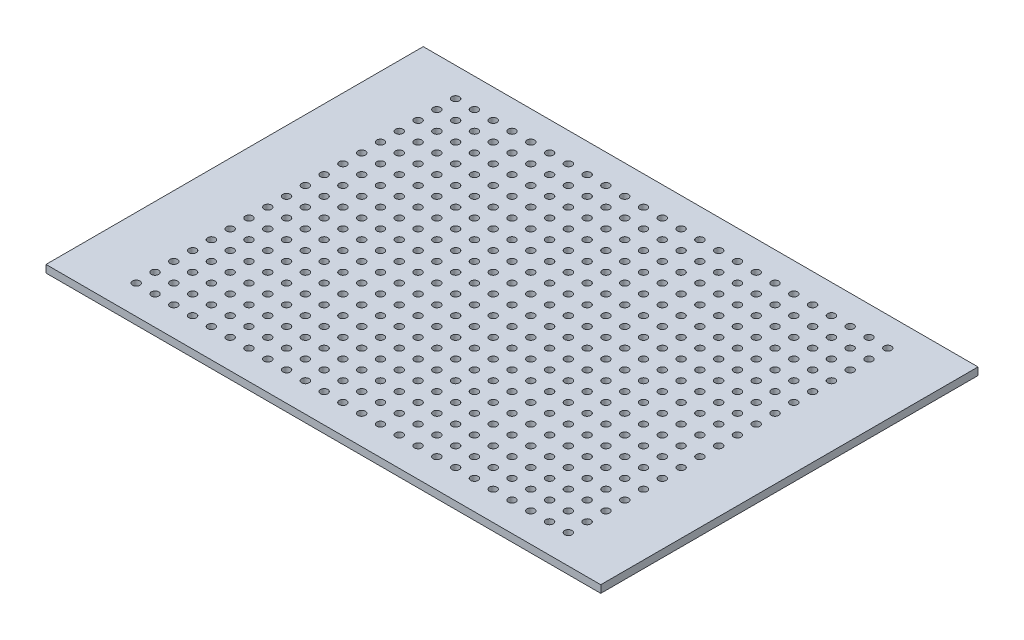
from build123d import *

# Parameters (mm, degrees)
SKETCH1_W           = 75
SKETCH1_H           = 51
SKETCH1_R           = 0.5
BOSS_EXTRUDE1_DEPTH = 1.016


with BuildPart() as part:
    # Sketch1 → Boss-Extrude1 (new body)
    with BuildSketch(Plane(origin=(0, 0, 0), x_dir=(1, 0, 0), z_dir=(0, 1, 0))):
        with Locations((37.5, 25.5)):
            Rectangle(SKETCH1_W, SKETCH1_H)
        with Locations((8.29, 3.91)):
            Circle(SKETCH1_R, mode=Mode.SUBTRACT)
        with Locations((10.83, 3.91)):
            Circle(SKETCH1_R, mode=Mode.SUBTRACT)
        with Locations((13.37, 3.91)):
            Circle(SKETCH1_R, mode=Mode.SUBTRACT)
        with Locations((15.91, 3.91)):
            Circle(SKETCH1_R, mode=Mode.SUBTRACT)
        with Locations((18.45, 3.91)):
            Circle(SKETCH1_R, mode=Mode.SUBTRACT)
        with Locations((20.99, 3.91)):
            Circle(SKETCH1_R, mode=Mode.SUBTRACT)
        with Locations((23.53, 3.91)):
            Circle(SKETCH1_R, mode=Mode.SUBTRACT)
        with Locations((26.07, 3.91)):
            Circle(SKETCH1_R, mode=Mode.SUBTRACT)
        with Locations((28.61, 3.91)):
            Circle(SKETCH1_R, mode=Mode.SUBTRACT)
        with Locations((31.15, 3.91)):
            Circle(SKETCH1_R, mode=Mode.SUBTRACT)
        with Locations((33.69, 3.91)):
            Circle(SKETCH1_R, mode=Mode.SUBTRACT)
        with Locations((36.23, 3.91)):
            Circle(SKETCH1_R, mode=Mode.SUBTRACT)
        with Locations((38.77, 3.91)):
            Circle(SKETCH1_R, mode=Mode.SUBTRACT)
        with Locations((41.31, 3.91)):
            Circle(SKETCH1_R, mode=Mode.SUBTRACT)
        with Locations((43.85, 3.91)):
            Circle(SKETCH1_R, mode=Mode.SUBTRACT)
        with Locations((46.39, 3.91)):
            Circle(SKETCH1_R, mode=Mode.SUBTRACT)
        with Locations((48.93, 3.91)):
            Circle(SKETCH1_R, mode=Mode.SUBTRACT)
        with Locations((51.47, 3.91)):
            Circle(SKETCH1_R, mode=Mode.SUBTRACT)
        with Locations((54.01, 3.91)):
            Circle(SKETCH1_R, mode=Mode.SUBTRACT)
        with Locations((56.55, 3.91)):
            Circle(SKETCH1_R, mode=Mode.SUBTRACT)
        with Locations((59.09, 3.91)):
            Circle(SKETCH1_R, mode=Mode.SUBTRACT)
        with Locations((61.63, 3.91)):
            Circle(SKETCH1_R, mode=Mode.SUBTRACT)
        with Locations((64.17, 3.91)):
            Circle(SKETCH1_R, mode=Mode.SUBTRACT)
        with Locations((66.71, 3.91)):
            Circle(SKETCH1_R, mode=Mode.SUBTRACT)
        with Locations((10.83, 6.45)):
            Circle(SKETCH1_R, mode=Mode.SUBTRACT)
        with Locations((13.37, 6.45)):
            Circle(SKETCH1_R, mode=Mode.SUBTRACT)
        with Locations((15.91, 6.45)):
            Circle(SKETCH1_R, mode=Mode.SUBTRACT)
        with Locations((18.45, 6.45)):
            Circle(SKETCH1_R, mode=Mode.SUBTRACT)
        with Locations((20.99, 6.45)):
            Circle(SKETCH1_R, mode=Mode.SUBTRACT)
        with Locations((23.53, 6.45)):
            Circle(SKETCH1_R, mode=Mode.SUBTRACT)
        with Locations((26.07, 6.45)):
            Circle(SKETCH1_R, mode=Mode.SUBTRACT)
        with Locations((28.61, 6.45)):
            Circle(SKETCH1_R, mode=Mode.SUBTRACT)
        with Locations((31.15, 6.45)):
            Circle(SKETCH1_R, mode=Mode.SUBTRACT)
        with Locations((33.69, 6.45)):
            Circle(SKETCH1_R, mode=Mode.SUBTRACT)
        with Locations((36.23, 6.45)):
            Circle(SKETCH1_R, mode=Mode.SUBTRACT)
        with Locations((38.77, 6.45)):
            Circle(SKETCH1_R, mode=Mode.SUBTRACT)
        with Locations((41.31, 6.45)):
            Circle(SKETCH1_R, mode=Mode.SUBTRACT)
        with Locations((43.85, 6.45)):
            Circle(SKETCH1_R, mode=Mode.SUBTRACT)
        with Locations((46.39, 6.45)):
            Circle(SKETCH1_R, mode=Mode.SUBTRACT)
        with Locations((48.93, 6.45)):
            Circle(SKETCH1_R, mode=Mode.SUBTRACT)
        with Locations((51.47, 6.45)):
            Circle(SKETCH1_R, mode=Mode.SUBTRACT)
        with Locations((54.01, 6.45)):
            Circle(SKETCH1_R, mode=Mode.SUBTRACT)
        with Locations((56.55, 6.45)):
            Circle(SKETCH1_R, mode=Mode.SUBTRACT)
        with Locations((59.09, 6.45)):
            Circle(SKETCH1_R, mode=Mode.SUBTRACT)
        with Locations((61.63, 6.45)):
            Circle(SKETCH1_R, mode=Mode.SUBTRACT)
        with Locations((64.17, 6.45)):
            Circle(SKETCH1_R, mode=Mode.SUBTRACT)
        with Locations((66.71, 6.45)):
            Circle(SKETCH1_R, mode=Mode.SUBTRACT)
        with Locations((10.83, 8.99)):
            Circle(SKETCH1_R, mode=Mode.SUBTRACT)
        with Locations((13.37, 8.99)):
            Circle(SKETCH1_R, mode=Mode.SUBTRACT)
        with Locations((15.91, 8.99)):
            Circle(SKETCH1_R, mode=Mode.SUBTRACT)
        with Locations((18.45, 8.99)):
            Circle(SKETCH1_R, mode=Mode.SUBTRACT)
        with Locations((20.99, 8.99)):
            Circle(SKETCH1_R, mode=Mode.SUBTRACT)
        with Locations((23.53, 8.99)):
            Circle(SKETCH1_R, mode=Mode.SUBTRACT)
        with Locations((26.07, 8.99)):
            Circle(SKETCH1_R, mode=Mode.SUBTRACT)
        with Locations((28.61, 8.99)):
            Circle(SKETCH1_R, mode=Mode.SUBTRACT)
        with Locations((31.15, 8.99)):
            Circle(SKETCH1_R, mode=Mode.SUBTRACT)
        with Locations((33.69, 8.99)):
            Circle(SKETCH1_R, mode=Mode.SUBTRACT)
        with Locations((36.23, 8.99)):
            Circle(SKETCH1_R, mode=Mode.SUBTRACT)
        with Locations((38.77, 8.99)):
            Circle(SKETCH1_R, mode=Mode.SUBTRACT)
        with Locations((41.31, 8.99)):
            Circle(SKETCH1_R, mode=Mode.SUBTRACT)
        with Locations((43.85, 8.99)):
            Circle(SKETCH1_R, mode=Mode.SUBTRACT)
        with Locations((46.39, 8.99)):
            Circle(SKETCH1_R, mode=Mode.SUBTRACT)
        with Locations((48.93, 8.99)):
            Circle(SKETCH1_R, mode=Mode.SUBTRACT)
        with Locations((51.47, 8.99)):
            Circle(SKETCH1_R, mode=Mode.SUBTRACT)
        with Locations((54.01, 8.99)):
            Circle(SKETCH1_R, mode=Mode.SUBTRACT)
        with Locations((56.55, 8.99)):
            Circle(SKETCH1_R, mode=Mode.SUBTRACT)
        with Locations((59.09, 8.99)):
            Circle(SKETCH1_R, mode=Mode.SUBTRACT)
        with Locations((61.63, 8.99)):
            Circle(SKETCH1_R, mode=Mode.SUBTRACT)
        with Locations((64.17, 8.99)):
            Circle(SKETCH1_R, mode=Mode.SUBTRACT)
        with Locations((66.71, 8.99)):
            Circle(SKETCH1_R, mode=Mode.SUBTRACT)
        with Locations((10.83, 11.53)):
            Circle(SKETCH1_R, mode=Mode.SUBTRACT)
        with Locations((13.37, 11.53)):
            Circle(SKETCH1_R, mode=Mode.SUBTRACT)
        with Locations((15.91, 11.53)):
            Circle(SKETCH1_R, mode=Mode.SUBTRACT)
        with Locations((18.45, 11.53)):
            Circle(SKETCH1_R, mode=Mode.SUBTRACT)
        with Locations((20.99, 11.53)):
            Circle(SKETCH1_R, mode=Mode.SUBTRACT)
        with Locations((23.53, 11.53)):
            Circle(SKETCH1_R, mode=Mode.SUBTRACT)
        with Locations((26.07, 11.53)):
            Circle(SKETCH1_R, mode=Mode.SUBTRACT)
        with Locations((28.61, 11.53)):
            Circle(SKETCH1_R, mode=Mode.SUBTRACT)
        with Locations((31.15, 11.53)):
            Circle(SKETCH1_R, mode=Mode.SUBTRACT)
        with Locations((33.69, 11.53)):
            Circle(SKETCH1_R, mode=Mode.SUBTRACT)
        with Locations((36.23, 11.53)):
            Circle(SKETCH1_R, mode=Mode.SUBTRACT)
        with Locations((38.77, 11.53)):
            Circle(SKETCH1_R, mode=Mode.SUBTRACT)
        with Locations((41.31, 11.53)):
            Circle(SKETCH1_R, mode=Mode.SUBTRACT)
        with Locations((43.85, 11.53)):
            Circle(SKETCH1_R, mode=Mode.SUBTRACT)
        with Locations((46.39, 11.53)):
            Circle(SKETCH1_R, mode=Mode.SUBTRACT)
        with Locations((48.93, 11.53)):
            Circle(SKETCH1_R, mode=Mode.SUBTRACT)
        with Locations((51.47, 11.53)):
            Circle(SKETCH1_R, mode=Mode.SUBTRACT)
        with Locations((54.01, 11.53)):
            Circle(SKETCH1_R, mode=Mode.SUBTRACT)
        with Locations((56.55, 11.53)):
            Circle(SKETCH1_R, mode=Mode.SUBTRACT)
        with Locations((59.09, 11.53)):
            Circle(SKETCH1_R, mode=Mode.SUBTRACT)
        with Locations((61.63, 11.53)):
            Circle(SKETCH1_R, mode=Mode.SUBTRACT)
        with Locations((64.17, 11.53)):
            Circle(SKETCH1_R, mode=Mode.SUBTRACT)
        with Locations((66.71, 11.53)):
            Circle(SKETCH1_R, mode=Mode.SUBTRACT)
        with Locations((10.83, 14.07)):
            Circle(SKETCH1_R, mode=Mode.SUBTRACT)
        with Locations((13.37, 14.07)):
            Circle(SKETCH1_R, mode=Mode.SUBTRACT)
        with Locations((15.91, 14.07)):
            Circle(SKETCH1_R, mode=Mode.SUBTRACT)
        with Locations((18.45, 14.07)):
            Circle(SKETCH1_R, mode=Mode.SUBTRACT)
        with Locations((20.99, 14.07)):
            Circle(SKETCH1_R, mode=Mode.SUBTRACT)
        with Locations((23.53, 14.07)):
            Circle(SKETCH1_R, mode=Mode.SUBTRACT)
        with Locations((26.07, 14.07)):
            Circle(SKETCH1_R, mode=Mode.SUBTRACT)
        with Locations((28.61, 14.07)):
            Circle(SKETCH1_R, mode=Mode.SUBTRACT)
        with Locations((31.15, 14.07)):
            Circle(SKETCH1_R, mode=Mode.SUBTRACT)
        with Locations((33.69, 14.07)):
            Circle(SKETCH1_R, mode=Mode.SUBTRACT)
        with Locations((36.23, 14.07)):
            Circle(SKETCH1_R, mode=Mode.SUBTRACT)
        with Locations((38.77, 14.07)):
            Circle(SKETCH1_R, mode=Mode.SUBTRACT)
        with Locations((41.31, 14.07)):
            Circle(SKETCH1_R, mode=Mode.SUBTRACT)
        with Locations((43.85, 14.07)):
            Circle(SKETCH1_R, mode=Mode.SUBTRACT)
        with Locations((46.39, 14.07)):
            Circle(SKETCH1_R, mode=Mode.SUBTRACT)
        with Locations((48.93, 14.07)):
            Circle(SKETCH1_R, mode=Mode.SUBTRACT)
        with Locations((51.47, 14.07)):
            Circle(SKETCH1_R, mode=Mode.SUBTRACT)
        with Locations((54.01, 14.07)):
            Circle(SKETCH1_R, mode=Mode.SUBTRACT)
        with Locations((56.55, 14.07)):
            Circle(SKETCH1_R, mode=Mode.SUBTRACT)
        with Locations((59.09, 14.07)):
            Circle(SKETCH1_R, mode=Mode.SUBTRACT)
        with Locations((61.63, 14.07)):
            Circle(SKETCH1_R, mode=Mode.SUBTRACT)
        with Locations((64.17, 14.07)):
            Circle(SKETCH1_R, mode=Mode.SUBTRACT)
        with Locations((66.71, 14.07)):
            Circle(SKETCH1_R, mode=Mode.SUBTRACT)
        with Locations((10.83, 16.61)):
            Circle(SKETCH1_R, mode=Mode.SUBTRACT)
        with Locations((13.37, 16.61)):
            Circle(SKETCH1_R, mode=Mode.SUBTRACT)
        with Locations((15.91, 16.61)):
            Circle(SKETCH1_R, mode=Mode.SUBTRACT)
        with Locations((18.45, 16.61)):
            Circle(SKETCH1_R, mode=Mode.SUBTRACT)
        with Locations((20.99, 16.61)):
            Circle(SKETCH1_R, mode=Mode.SUBTRACT)
        with Locations((23.53, 16.61)):
            Circle(SKETCH1_R, mode=Mode.SUBTRACT)
        with Locations((26.07, 16.61)):
            Circle(SKETCH1_R, mode=Mode.SUBTRACT)
        with Locations((28.61, 16.61)):
            Circle(SKETCH1_R, mode=Mode.SUBTRACT)
        with Locations((31.15, 16.61)):
            Circle(SKETCH1_R, mode=Mode.SUBTRACT)
        with Locations((33.69, 16.61)):
            Circle(SKETCH1_R, mode=Mode.SUBTRACT)
        with Locations((36.23, 16.61)):
            Circle(SKETCH1_R, mode=Mode.SUBTRACT)
        with Locations((38.77, 16.61)):
            Circle(SKETCH1_R, mode=Mode.SUBTRACT)
        with Locations((41.31, 16.61)):
            Circle(SKETCH1_R, mode=Mode.SUBTRACT)
        with Locations((43.85, 16.61)):
            Circle(SKETCH1_R, mode=Mode.SUBTRACT)
        with Locations((46.39, 16.61)):
            Circle(SKETCH1_R, mode=Mode.SUBTRACT)
        with Locations((48.93, 16.61)):
            Circle(SKETCH1_R, mode=Mode.SUBTRACT)
        with Locations((51.47, 16.61)):
            Circle(SKETCH1_R, mode=Mode.SUBTRACT)
        with Locations((54.01, 16.61)):
            Circle(SKETCH1_R, mode=Mode.SUBTRACT)
        with Locations((56.55, 16.61)):
            Circle(SKETCH1_R, mode=Mode.SUBTRACT)
        with Locations((59.09, 16.61)):
            Circle(SKETCH1_R, mode=Mode.SUBTRACT)
        with Locations((61.63, 16.61)):
            Circle(SKETCH1_R, mode=Mode.SUBTRACT)
        with Locations((64.17, 16.61)):
            Circle(SKETCH1_R, mode=Mode.SUBTRACT)
        with Locations((66.71, 16.61)):
            Circle(SKETCH1_R, mode=Mode.SUBTRACT)
        with Locations((10.83, 19.15)):
            Circle(SKETCH1_R, mode=Mode.SUBTRACT)
        with Locations((13.37, 19.15)):
            Circle(SKETCH1_R, mode=Mode.SUBTRACT)
        with Locations((15.91, 19.15)):
            Circle(SKETCH1_R, mode=Mode.SUBTRACT)
        with Locations((18.45, 19.15)):
            Circle(SKETCH1_R, mode=Mode.SUBTRACT)
        with Locations((20.99, 19.15)):
            Circle(SKETCH1_R, mode=Mode.SUBTRACT)
        with Locations((23.53, 19.15)):
            Circle(SKETCH1_R, mode=Mode.SUBTRACT)
        with Locations((26.07, 19.15)):
            Circle(SKETCH1_R, mode=Mode.SUBTRACT)
        with Locations((28.61, 19.15)):
            Circle(SKETCH1_R, mode=Mode.SUBTRACT)
        with Locations((31.15, 19.15)):
            Circle(SKETCH1_R, mode=Mode.SUBTRACT)
        with Locations((33.69, 19.15)):
            Circle(SKETCH1_R, mode=Mode.SUBTRACT)
        with Locations((36.23, 19.15)):
            Circle(SKETCH1_R, mode=Mode.SUBTRACT)
        with Locations((38.77, 19.15)):
            Circle(SKETCH1_R, mode=Mode.SUBTRACT)
        with Locations((41.31, 19.15)):
            Circle(SKETCH1_R, mode=Mode.SUBTRACT)
        with Locations((43.85, 19.15)):
            Circle(SKETCH1_R, mode=Mode.SUBTRACT)
        with Locations((46.39, 19.15)):
            Circle(SKETCH1_R, mode=Mode.SUBTRACT)
        with Locations((48.93, 19.15)):
            Circle(SKETCH1_R, mode=Mode.SUBTRACT)
        with Locations((51.47, 19.15)):
            Circle(SKETCH1_R, mode=Mode.SUBTRACT)
        with Locations((54.01, 19.15)):
            Circle(SKETCH1_R, mode=Mode.SUBTRACT)
        with Locations((56.55, 19.15)):
            Circle(SKETCH1_R, mode=Mode.SUBTRACT)
        with Locations((59.09, 19.15)):
            Circle(SKETCH1_R, mode=Mode.SUBTRACT)
        with Locations((61.63, 19.15)):
            Circle(SKETCH1_R, mode=Mode.SUBTRACT)
        with Locations((64.17, 19.15)):
            Circle(SKETCH1_R, mode=Mode.SUBTRACT)
        with Locations((66.71, 19.15)):
            Circle(SKETCH1_R, mode=Mode.SUBTRACT)
        with Locations((10.83, 21.69)):
            Circle(SKETCH1_R, mode=Mode.SUBTRACT)
        with Locations((13.37, 21.69)):
            Circle(SKETCH1_R, mode=Mode.SUBTRACT)
        with Locations((15.91, 21.69)):
            Circle(SKETCH1_R, mode=Mode.SUBTRACT)
        with Locations((18.45, 21.69)):
            Circle(SKETCH1_R, mode=Mode.SUBTRACT)
        with Locations((20.99, 21.69)):
            Circle(SKETCH1_R, mode=Mode.SUBTRACT)
        with Locations((23.53, 21.69)):
            Circle(SKETCH1_R, mode=Mode.SUBTRACT)
        with Locations((26.07, 21.69)):
            Circle(SKETCH1_R, mode=Mode.SUBTRACT)
        with Locations((28.61, 21.69)):
            Circle(SKETCH1_R, mode=Mode.SUBTRACT)
        with Locations((31.15, 21.69)):
            Circle(SKETCH1_R, mode=Mode.SUBTRACT)
        with Locations((33.69, 21.69)):
            Circle(SKETCH1_R, mode=Mode.SUBTRACT)
        with Locations((36.23, 21.69)):
            Circle(SKETCH1_R, mode=Mode.SUBTRACT)
        with Locations((38.77, 21.69)):
            Circle(SKETCH1_R, mode=Mode.SUBTRACT)
        with Locations((41.31, 21.69)):
            Circle(SKETCH1_R, mode=Mode.SUBTRACT)
        with Locations((43.85, 21.69)):
            Circle(SKETCH1_R, mode=Mode.SUBTRACT)
        with Locations((46.39, 21.69)):
            Circle(SKETCH1_R, mode=Mode.SUBTRACT)
        with Locations((48.93, 21.69)):
            Circle(SKETCH1_R, mode=Mode.SUBTRACT)
        with Locations((51.47, 21.69)):
            Circle(SKETCH1_R, mode=Mode.SUBTRACT)
        with Locations((54.01, 21.69)):
            Circle(SKETCH1_R, mode=Mode.SUBTRACT)
        with Locations((56.55, 21.69)):
            Circle(SKETCH1_R, mode=Mode.SUBTRACT)
        with Locations((59.09, 21.69)):
            Circle(SKETCH1_R, mode=Mode.SUBTRACT)
        with Locations((61.63, 21.69)):
            Circle(SKETCH1_R, mode=Mode.SUBTRACT)
        with Locations((64.17, 21.69)):
            Circle(SKETCH1_R, mode=Mode.SUBTRACT)
        with Locations((66.71, 21.69)):
            Circle(SKETCH1_R, mode=Mode.SUBTRACT)
        with Locations((10.83, 24.23)):
            Circle(SKETCH1_R, mode=Mode.SUBTRACT)
        with Locations((13.37, 24.23)):
            Circle(SKETCH1_R, mode=Mode.SUBTRACT)
        with Locations((15.91, 24.23)):
            Circle(SKETCH1_R, mode=Mode.SUBTRACT)
        with Locations((18.45, 24.23)):
            Circle(SKETCH1_R, mode=Mode.SUBTRACT)
        with Locations((20.99, 24.23)):
            Circle(SKETCH1_R, mode=Mode.SUBTRACT)
        with Locations((23.53, 24.23)):
            Circle(SKETCH1_R, mode=Mode.SUBTRACT)
        with Locations((26.07, 24.23)):
            Circle(SKETCH1_R, mode=Mode.SUBTRACT)
        with Locations((28.61, 24.23)):
            Circle(SKETCH1_R, mode=Mode.SUBTRACT)
        with Locations((31.15, 24.23)):
            Circle(SKETCH1_R, mode=Mode.SUBTRACT)
        with Locations((33.69, 24.23)):
            Circle(SKETCH1_R, mode=Mode.SUBTRACT)
        with Locations((36.23, 24.23)):
            Circle(SKETCH1_R, mode=Mode.SUBTRACT)
        with Locations((38.77, 24.23)):
            Circle(SKETCH1_R, mode=Mode.SUBTRACT)
        with Locations((41.31, 24.23)):
            Circle(SKETCH1_R, mode=Mode.SUBTRACT)
        with Locations((43.85, 24.23)):
            Circle(SKETCH1_R, mode=Mode.SUBTRACT)
        with Locations((46.39, 24.23)):
            Circle(SKETCH1_R, mode=Mode.SUBTRACT)
        with Locations((48.93, 24.23)):
            Circle(SKETCH1_R, mode=Mode.SUBTRACT)
        with Locations((51.47, 24.23)):
            Circle(SKETCH1_R, mode=Mode.SUBTRACT)
        with Locations((54.01, 24.23)):
            Circle(SKETCH1_R, mode=Mode.SUBTRACT)
        with Locations((56.55, 24.23)):
            Circle(SKETCH1_R, mode=Mode.SUBTRACT)
        with Locations((59.09, 24.23)):
            Circle(SKETCH1_R, mode=Mode.SUBTRACT)
        with Locations((61.63, 24.23)):
            Circle(SKETCH1_R, mode=Mode.SUBTRACT)
        with Locations((64.17, 24.23)):
            Circle(SKETCH1_R, mode=Mode.SUBTRACT)
        with Locations((66.71, 24.23)):
            Circle(SKETCH1_R, mode=Mode.SUBTRACT)
        with Locations((10.83, 26.77)):
            Circle(SKETCH1_R, mode=Mode.SUBTRACT)
        with Locations((13.37, 26.77)):
            Circle(SKETCH1_R, mode=Mode.SUBTRACT)
        with Locations((15.91, 26.77)):
            Circle(SKETCH1_R, mode=Mode.SUBTRACT)
        with Locations((18.45, 26.77)):
            Circle(SKETCH1_R, mode=Mode.SUBTRACT)
        with Locations((20.99, 26.77)):
            Circle(SKETCH1_R, mode=Mode.SUBTRACT)
        with Locations((23.53, 26.77)):
            Circle(SKETCH1_R, mode=Mode.SUBTRACT)
        with Locations((26.07, 26.77)):
            Circle(SKETCH1_R, mode=Mode.SUBTRACT)
        with Locations((28.61, 26.77)):
            Circle(SKETCH1_R, mode=Mode.SUBTRACT)
        with Locations((31.15, 26.77)):
            Circle(SKETCH1_R, mode=Mode.SUBTRACT)
        with Locations((33.69, 26.77)):
            Circle(SKETCH1_R, mode=Mode.SUBTRACT)
        with Locations((36.23, 26.77)):
            Circle(SKETCH1_R, mode=Mode.SUBTRACT)
        with Locations((38.77, 26.77)):
            Circle(SKETCH1_R, mode=Mode.SUBTRACT)
        with Locations((41.31, 26.77)):
            Circle(SKETCH1_R, mode=Mode.SUBTRACT)
        with Locations((43.85, 26.77)):
            Circle(SKETCH1_R, mode=Mode.SUBTRACT)
        with Locations((46.39, 26.77)):
            Circle(SKETCH1_R, mode=Mode.SUBTRACT)
        with Locations((48.93, 26.77)):
            Circle(SKETCH1_R, mode=Mode.SUBTRACT)
        with Locations((51.47, 26.77)):
            Circle(SKETCH1_R, mode=Mode.SUBTRACT)
        with Locations((54.01, 26.77)):
            Circle(SKETCH1_R, mode=Mode.SUBTRACT)
        with Locations((56.55, 26.77)):
            Circle(SKETCH1_R, mode=Mode.SUBTRACT)
        with Locations((59.09, 26.77)):
            Circle(SKETCH1_R, mode=Mode.SUBTRACT)
        with Locations((61.63, 26.77)):
            Circle(SKETCH1_R, mode=Mode.SUBTRACT)
        with Locations((64.17, 26.77)):
            Circle(SKETCH1_R, mode=Mode.SUBTRACT)
        with Locations((66.71, 26.77)):
            Circle(SKETCH1_R, mode=Mode.SUBTRACT)
        with Locations((10.83, 29.31)):
            Circle(SKETCH1_R, mode=Mode.SUBTRACT)
        with Locations((13.37, 29.31)):
            Circle(SKETCH1_R, mode=Mode.SUBTRACT)
        with Locations((15.91, 29.31)):
            Circle(SKETCH1_R, mode=Mode.SUBTRACT)
        with Locations((18.45, 29.31)):
            Circle(SKETCH1_R, mode=Mode.SUBTRACT)
        with Locations((20.99, 29.31)):
            Circle(SKETCH1_R, mode=Mode.SUBTRACT)
        with Locations((23.53, 29.31)):
            Circle(SKETCH1_R, mode=Mode.SUBTRACT)
        with Locations((26.07, 29.31)):
            Circle(SKETCH1_R, mode=Mode.SUBTRACT)
        with Locations((28.61, 29.31)):
            Circle(SKETCH1_R, mode=Mode.SUBTRACT)
        with Locations((31.15, 29.31)):
            Circle(SKETCH1_R, mode=Mode.SUBTRACT)
        with Locations((33.69, 29.31)):
            Circle(SKETCH1_R, mode=Mode.SUBTRACT)
        with Locations((36.23, 29.31)):
            Circle(SKETCH1_R, mode=Mode.SUBTRACT)
        with Locations((38.77, 29.31)):
            Circle(SKETCH1_R, mode=Mode.SUBTRACT)
        with Locations((41.31, 29.31)):
            Circle(SKETCH1_R, mode=Mode.SUBTRACT)
        with Locations((43.85, 29.31)):
            Circle(SKETCH1_R, mode=Mode.SUBTRACT)
        with Locations((46.39, 29.31)):
            Circle(SKETCH1_R, mode=Mode.SUBTRACT)
        with Locations((48.93, 29.31)):
            Circle(SKETCH1_R, mode=Mode.SUBTRACT)
        with Locations((51.47, 29.31)):
            Circle(SKETCH1_R, mode=Mode.SUBTRACT)
        with Locations((54.01, 29.31)):
            Circle(SKETCH1_R, mode=Mode.SUBTRACT)
        with Locations((56.55, 29.31)):
            Circle(SKETCH1_R, mode=Mode.SUBTRACT)
        with Locations((59.09, 29.31)):
            Circle(SKETCH1_R, mode=Mode.SUBTRACT)
        with Locations((61.63, 29.31)):
            Circle(SKETCH1_R, mode=Mode.SUBTRACT)
        with Locations((64.17, 29.31)):
            Circle(SKETCH1_R, mode=Mode.SUBTRACT)
        with Locations((66.71, 29.31)):
            Circle(SKETCH1_R, mode=Mode.SUBTRACT)
        with Locations((10.83, 31.85)):
            Circle(SKETCH1_R, mode=Mode.SUBTRACT)
        with Locations((13.37, 31.85)):
            Circle(SKETCH1_R, mode=Mode.SUBTRACT)
        with Locations((15.91, 31.85)):
            Circle(SKETCH1_R, mode=Mode.SUBTRACT)
        with Locations((18.45, 31.85)):
            Circle(SKETCH1_R, mode=Mode.SUBTRACT)
        with Locations((20.99, 31.85)):
            Circle(SKETCH1_R, mode=Mode.SUBTRACT)
        with Locations((23.53, 31.85)):
            Circle(SKETCH1_R, mode=Mode.SUBTRACT)
        with Locations((26.07, 31.85)):
            Circle(SKETCH1_R, mode=Mode.SUBTRACT)
        with Locations((28.61, 31.85)):
            Circle(SKETCH1_R, mode=Mode.SUBTRACT)
        with Locations((31.15, 31.85)):
            Circle(SKETCH1_R, mode=Mode.SUBTRACT)
        with Locations((33.69, 31.85)):
            Circle(SKETCH1_R, mode=Mode.SUBTRACT)
        with Locations((36.23, 31.85)):
            Circle(SKETCH1_R, mode=Mode.SUBTRACT)
        with Locations((38.77, 31.85)):
            Circle(SKETCH1_R, mode=Mode.SUBTRACT)
        with Locations((41.31, 31.85)):
            Circle(SKETCH1_R, mode=Mode.SUBTRACT)
        with Locations((43.85, 31.85)):
            Circle(SKETCH1_R, mode=Mode.SUBTRACT)
        with Locations((46.39, 31.85)):
            Circle(SKETCH1_R, mode=Mode.SUBTRACT)
        with Locations((48.93, 31.85)):
            Circle(SKETCH1_R, mode=Mode.SUBTRACT)
        with Locations((51.47, 31.85)):
            Circle(SKETCH1_R, mode=Mode.SUBTRACT)
        with Locations((54.01, 31.85)):
            Circle(SKETCH1_R, mode=Mode.SUBTRACT)
        with Locations((56.55, 31.85)):
            Circle(SKETCH1_R, mode=Mode.SUBTRACT)
        with Locations((59.09, 31.85)):
            Circle(SKETCH1_R, mode=Mode.SUBTRACT)
        with Locations((61.63, 31.85)):
            Circle(SKETCH1_R, mode=Mode.SUBTRACT)
        with Locations((64.17, 31.85)):
            Circle(SKETCH1_R, mode=Mode.SUBTRACT)
        with Locations((66.71, 31.85)):
            Circle(SKETCH1_R, mode=Mode.SUBTRACT)
        with Locations((10.83, 34.39)):
            Circle(SKETCH1_R, mode=Mode.SUBTRACT)
        with Locations((13.37, 34.39)):
            Circle(SKETCH1_R, mode=Mode.SUBTRACT)
        with Locations((15.91, 34.39)):
            Circle(SKETCH1_R, mode=Mode.SUBTRACT)
        with Locations((18.45, 34.39)):
            Circle(SKETCH1_R, mode=Mode.SUBTRACT)
        with Locations((20.99, 34.39)):
            Circle(SKETCH1_R, mode=Mode.SUBTRACT)
        with Locations((23.53, 34.39)):
            Circle(SKETCH1_R, mode=Mode.SUBTRACT)
        with Locations((26.07, 34.39)):
            Circle(SKETCH1_R, mode=Mode.SUBTRACT)
        with Locations((28.61, 34.39)):
            Circle(SKETCH1_R, mode=Mode.SUBTRACT)
        with Locations((31.15, 34.39)):
            Circle(SKETCH1_R, mode=Mode.SUBTRACT)
        with Locations((33.69, 34.39)):
            Circle(SKETCH1_R, mode=Mode.SUBTRACT)
        with Locations((36.23, 34.39)):
            Circle(SKETCH1_R, mode=Mode.SUBTRACT)
        with Locations((38.77, 34.39)):
            Circle(SKETCH1_R, mode=Mode.SUBTRACT)
        with Locations((41.31, 34.39)):
            Circle(SKETCH1_R, mode=Mode.SUBTRACT)
        with Locations((43.85, 34.39)):
            Circle(SKETCH1_R, mode=Mode.SUBTRACT)
        with Locations((46.39, 34.39)):
            Circle(SKETCH1_R, mode=Mode.SUBTRACT)
        with Locations((48.93, 34.39)):
            Circle(SKETCH1_R, mode=Mode.SUBTRACT)
        with Locations((51.47, 34.39)):
            Circle(SKETCH1_R, mode=Mode.SUBTRACT)
        with Locations((54.01, 34.39)):
            Circle(SKETCH1_R, mode=Mode.SUBTRACT)
        with Locations((56.55, 34.39)):
            Circle(SKETCH1_R, mode=Mode.SUBTRACT)
        with Locations((59.09, 34.39)):
            Circle(SKETCH1_R, mode=Mode.SUBTRACT)
        with Locations((61.63, 34.39)):
            Circle(SKETCH1_R, mode=Mode.SUBTRACT)
        with Locations((64.17, 34.39)):
            Circle(SKETCH1_R, mode=Mode.SUBTRACT)
        with Locations((66.71, 34.39)):
            Circle(SKETCH1_R, mode=Mode.SUBTRACT)
        with Locations((10.83, 36.93)):
            Circle(SKETCH1_R, mode=Mode.SUBTRACT)
        with Locations((13.37, 36.93)):
            Circle(SKETCH1_R, mode=Mode.SUBTRACT)
        with Locations((15.91, 36.93)):
            Circle(SKETCH1_R, mode=Mode.SUBTRACT)
        with Locations((18.45, 36.93)):
            Circle(SKETCH1_R, mode=Mode.SUBTRACT)
        with Locations((20.99, 36.93)):
            Circle(SKETCH1_R, mode=Mode.SUBTRACT)
        with Locations((23.53, 36.93)):
            Circle(SKETCH1_R, mode=Mode.SUBTRACT)
        with Locations((26.07, 36.93)):
            Circle(SKETCH1_R, mode=Mode.SUBTRACT)
        with Locations((28.61, 36.93)):
            Circle(SKETCH1_R, mode=Mode.SUBTRACT)
        with Locations((31.15, 36.93)):
            Circle(SKETCH1_R, mode=Mode.SUBTRACT)
        with Locations((33.69, 36.93)):
            Circle(SKETCH1_R, mode=Mode.SUBTRACT)
        with Locations((36.23, 36.93)):
            Circle(SKETCH1_R, mode=Mode.SUBTRACT)
        with Locations((38.77, 36.93)):
            Circle(SKETCH1_R, mode=Mode.SUBTRACT)
        with Locations((41.31, 36.93)):
            Circle(SKETCH1_R, mode=Mode.SUBTRACT)
        with Locations((43.85, 36.93)):
            Circle(SKETCH1_R, mode=Mode.SUBTRACT)
        with Locations((46.39, 36.93)):
            Circle(SKETCH1_R, mode=Mode.SUBTRACT)
        with Locations((48.93, 36.93)):
            Circle(SKETCH1_R, mode=Mode.SUBTRACT)
        with Locations((51.47, 36.93)):
            Circle(SKETCH1_R, mode=Mode.SUBTRACT)
        with Locations((54.01, 36.93)):
            Circle(SKETCH1_R, mode=Mode.SUBTRACT)
        with Locations((56.55, 36.93)):
            Circle(SKETCH1_R, mode=Mode.SUBTRACT)
        with Locations((59.09, 36.93)):
            Circle(SKETCH1_R, mode=Mode.SUBTRACT)
        with Locations((61.63, 36.93)):
            Circle(SKETCH1_R, mode=Mode.SUBTRACT)
        with Locations((64.17, 36.93)):
            Circle(SKETCH1_R, mode=Mode.SUBTRACT)
        with Locations((66.71, 36.93)):
            Circle(SKETCH1_R, mode=Mode.SUBTRACT)
        with Locations((10.83, 39.47)):
            Circle(SKETCH1_R, mode=Mode.SUBTRACT)
        with Locations((13.37, 39.47)):
            Circle(SKETCH1_R, mode=Mode.SUBTRACT)
        with Locations((15.91, 39.47)):
            Circle(SKETCH1_R, mode=Mode.SUBTRACT)
        with Locations((18.45, 39.47)):
            Circle(SKETCH1_R, mode=Mode.SUBTRACT)
        with Locations((20.99, 39.47)):
            Circle(SKETCH1_R, mode=Mode.SUBTRACT)
        with Locations((23.53, 39.47)):
            Circle(SKETCH1_R, mode=Mode.SUBTRACT)
        with Locations((26.07, 39.47)):
            Circle(SKETCH1_R, mode=Mode.SUBTRACT)
        with Locations((28.61, 39.47)):
            Circle(SKETCH1_R, mode=Mode.SUBTRACT)
        with Locations((31.15, 39.47)):
            Circle(SKETCH1_R, mode=Mode.SUBTRACT)
        with Locations((33.69, 39.47)):
            Circle(SKETCH1_R, mode=Mode.SUBTRACT)
        with Locations((36.23, 39.47)):
            Circle(SKETCH1_R, mode=Mode.SUBTRACT)
        with Locations((38.77, 39.47)):
            Circle(SKETCH1_R, mode=Mode.SUBTRACT)
        with Locations((41.31, 39.47)):
            Circle(SKETCH1_R, mode=Mode.SUBTRACT)
        with Locations((43.85, 39.47)):
            Circle(SKETCH1_R, mode=Mode.SUBTRACT)
        with Locations((46.39, 39.47)):
            Circle(SKETCH1_R, mode=Mode.SUBTRACT)
        with Locations((48.93, 39.47)):
            Circle(SKETCH1_R, mode=Mode.SUBTRACT)
        with Locations((51.47, 39.47)):
            Circle(SKETCH1_R, mode=Mode.SUBTRACT)
        with Locations((54.01, 39.47)):
            Circle(SKETCH1_R, mode=Mode.SUBTRACT)
        with Locations((56.55, 39.47)):
            Circle(SKETCH1_R, mode=Mode.SUBTRACT)
        with Locations((59.09, 39.47)):
            Circle(SKETCH1_R, mode=Mode.SUBTRACT)
        with Locations((61.63, 39.47)):
            Circle(SKETCH1_R, mode=Mode.SUBTRACT)
        with Locations((64.17, 39.47)):
            Circle(SKETCH1_R, mode=Mode.SUBTRACT)
        with Locations((66.71, 39.47)):
            Circle(SKETCH1_R, mode=Mode.SUBTRACT)
        with Locations((10.83, 42.01)):
            Circle(SKETCH1_R, mode=Mode.SUBTRACT)
        with Locations((13.37, 42.01)):
            Circle(SKETCH1_R, mode=Mode.SUBTRACT)
        with Locations((15.91, 42.01)):
            Circle(SKETCH1_R, mode=Mode.SUBTRACT)
        with Locations((18.45, 42.01)):
            Circle(SKETCH1_R, mode=Mode.SUBTRACT)
        with Locations((20.99, 42.01)):
            Circle(SKETCH1_R, mode=Mode.SUBTRACT)
        with Locations((23.53, 42.01)):
            Circle(SKETCH1_R, mode=Mode.SUBTRACT)
        with Locations((26.07, 42.01)):
            Circle(SKETCH1_R, mode=Mode.SUBTRACT)
        with Locations((28.61, 42.01)):
            Circle(SKETCH1_R, mode=Mode.SUBTRACT)
        with Locations((31.15, 42.01)):
            Circle(SKETCH1_R, mode=Mode.SUBTRACT)
        with Locations((33.69, 42.01)):
            Circle(SKETCH1_R, mode=Mode.SUBTRACT)
        with Locations((36.23, 42.01)):
            Circle(SKETCH1_R, mode=Mode.SUBTRACT)
        with Locations((38.77, 42.01)):
            Circle(SKETCH1_R, mode=Mode.SUBTRACT)
        with Locations((41.31, 42.01)):
            Circle(SKETCH1_R, mode=Mode.SUBTRACT)
        with Locations((43.85, 42.01)):
            Circle(SKETCH1_R, mode=Mode.SUBTRACT)
        with Locations((46.39, 42.01)):
            Circle(SKETCH1_R, mode=Mode.SUBTRACT)
        with Locations((48.93, 42.01)):
            Circle(SKETCH1_R, mode=Mode.SUBTRACT)
        with Locations((51.47, 42.01)):
            Circle(SKETCH1_R, mode=Mode.SUBTRACT)
        with Locations((54.01, 42.01)):
            Circle(SKETCH1_R, mode=Mode.SUBTRACT)
        with Locations((56.55, 42.01)):
            Circle(SKETCH1_R, mode=Mode.SUBTRACT)
        with Locations((59.09, 42.01)):
            Circle(SKETCH1_R, mode=Mode.SUBTRACT)
        with Locations((61.63, 42.01)):
            Circle(SKETCH1_R, mode=Mode.SUBTRACT)
        with Locations((64.17, 42.01)):
            Circle(SKETCH1_R, mode=Mode.SUBTRACT)
        with Locations((66.71, 42.01)):
            Circle(SKETCH1_R, mode=Mode.SUBTRACT)
        with Locations((10.83, 44.55)):
            Circle(SKETCH1_R, mode=Mode.SUBTRACT)
        with Locations((13.37, 44.55)):
            Circle(SKETCH1_R, mode=Mode.SUBTRACT)
        with Locations((15.91, 44.55)):
            Circle(SKETCH1_R, mode=Mode.SUBTRACT)
        with Locations((18.45, 44.55)):
            Circle(SKETCH1_R, mode=Mode.SUBTRACT)
        with Locations((20.99, 44.55)):
            Circle(SKETCH1_R, mode=Mode.SUBTRACT)
        with Locations((23.53, 44.55)):
            Circle(SKETCH1_R, mode=Mode.SUBTRACT)
        with Locations((26.07, 44.55)):
            Circle(SKETCH1_R, mode=Mode.SUBTRACT)
        with Locations((28.61, 44.55)):
            Circle(SKETCH1_R, mode=Mode.SUBTRACT)
        with Locations((31.15, 44.55)):
            Circle(SKETCH1_R, mode=Mode.SUBTRACT)
        with Locations((33.69, 44.55)):
            Circle(SKETCH1_R, mode=Mode.SUBTRACT)
        with Locations((36.23, 44.55)):
            Circle(SKETCH1_R, mode=Mode.SUBTRACT)
        with Locations((38.77, 44.55)):
            Circle(SKETCH1_R, mode=Mode.SUBTRACT)
        with Locations((41.31, 44.55)):
            Circle(SKETCH1_R, mode=Mode.SUBTRACT)
        with Locations((43.85, 44.55)):
            Circle(SKETCH1_R, mode=Mode.SUBTRACT)
        with Locations((46.39, 44.55)):
            Circle(SKETCH1_R, mode=Mode.SUBTRACT)
        with Locations((48.93, 44.55)):
            Circle(SKETCH1_R, mode=Mode.SUBTRACT)
        with Locations((51.47, 44.55)):
            Circle(SKETCH1_R, mode=Mode.SUBTRACT)
        with Locations((54.01, 44.55)):
            Circle(SKETCH1_R, mode=Mode.SUBTRACT)
        with Locations((56.55, 44.55)):
            Circle(SKETCH1_R, mode=Mode.SUBTRACT)
        with Locations((59.09, 44.55)):
            Circle(SKETCH1_R, mode=Mode.SUBTRACT)
        with Locations((61.63, 44.55)):
            Circle(SKETCH1_R, mode=Mode.SUBTRACT)
        with Locations((64.17, 44.55)):
            Circle(SKETCH1_R, mode=Mode.SUBTRACT)
        with Locations((66.71, 44.55)):
            Circle(SKETCH1_R, mode=Mode.SUBTRACT)
        with Locations((10.83, 47.09)):
            Circle(SKETCH1_R, mode=Mode.SUBTRACT)
        with Locations((13.37, 47.09)):
            Circle(SKETCH1_R, mode=Mode.SUBTRACT)
        with Locations((15.91, 47.09)):
            Circle(SKETCH1_R, mode=Mode.SUBTRACT)
        with Locations((18.45, 47.09)):
            Circle(SKETCH1_R, mode=Mode.SUBTRACT)
        with Locations((20.99, 47.09)):
            Circle(SKETCH1_R, mode=Mode.SUBTRACT)
        with Locations((23.53, 47.09)):
            Circle(SKETCH1_R, mode=Mode.SUBTRACT)
        with Locations((26.07, 47.09)):
            Circle(SKETCH1_R, mode=Mode.SUBTRACT)
        with Locations((28.61, 47.09)):
            Circle(SKETCH1_R, mode=Mode.SUBTRACT)
        with Locations((31.15, 47.09)):
            Circle(SKETCH1_R, mode=Mode.SUBTRACT)
        with Locations((33.69, 47.09)):
            Circle(SKETCH1_R, mode=Mode.SUBTRACT)
        with Locations((36.23, 47.09)):
            Circle(SKETCH1_R, mode=Mode.SUBTRACT)
        with Locations((38.77, 47.09)):
            Circle(SKETCH1_R, mode=Mode.SUBTRACT)
        with Locations((41.31, 47.09)):
            Circle(SKETCH1_R, mode=Mode.SUBTRACT)
        with Locations((43.85, 47.09)):
            Circle(SKETCH1_R, mode=Mode.SUBTRACT)
        with Locations((46.39, 47.09)):
            Circle(SKETCH1_R, mode=Mode.SUBTRACT)
        with Locations((48.93, 47.09)):
            Circle(SKETCH1_R, mode=Mode.SUBTRACT)
        with Locations((51.47, 47.09)):
            Circle(SKETCH1_R, mode=Mode.SUBTRACT)
        with Locations((54.01, 47.09)):
            Circle(SKETCH1_R, mode=Mode.SUBTRACT)
        with Locations((56.55, 47.09)):
            Circle(SKETCH1_R, mode=Mode.SUBTRACT)
        with Locations((59.09, 47.09)):
            Circle(SKETCH1_R, mode=Mode.SUBTRACT)
        with Locations((61.63, 47.09)):
            Circle(SKETCH1_R, mode=Mode.SUBTRACT)
        with Locations((64.17, 47.09)):
            Circle(SKETCH1_R, mode=Mode.SUBTRACT)
        with Locations((66.71, 47.09)):
            Circle(SKETCH1_R, mode=Mode.SUBTRACT)
        with Locations((8.29, 6.45)):
            Circle(SKETCH1_R, mode=Mode.SUBTRACT)
        with Locations((8.29, 8.99)):
            Circle(SKETCH1_R, mode=Mode.SUBTRACT)
        with Locations((8.29, 11.53)):
            Circle(SKETCH1_R, mode=Mode.SUBTRACT)
        with Locations((8.29, 14.07)):
            Circle(SKETCH1_R, mode=Mode.SUBTRACT)
        with Locations((8.29, 16.61)):
            Circle(SKETCH1_R, mode=Mode.SUBTRACT)
        with Locations((8.29, 19.15)):
            Circle(SKETCH1_R, mode=Mode.SUBTRACT)
        with Locations((8.29, 21.69)):
            Circle(SKETCH1_R, mode=Mode.SUBTRACT)
        with Locations((8.29, 24.23)):
            Circle(SKETCH1_R, mode=Mode.SUBTRACT)
        with Locations((8.29, 26.77)):
            Circle(SKETCH1_R, mode=Mode.SUBTRACT)
        with Locations((8.29, 29.31)):
            Circle(SKETCH1_R, mode=Mode.SUBTRACT)
        with Locations((8.29, 31.85)):
            Circle(SKETCH1_R, mode=Mode.SUBTRACT)
        with Locations((8.29, 34.39)):
            Circle(SKETCH1_R, mode=Mode.SUBTRACT)
        with Locations((8.29, 36.93)):
            Circle(SKETCH1_R, mode=Mode.SUBTRACT)
        with Locations((8.29, 39.47)):
            Circle(SKETCH1_R, mode=Mode.SUBTRACT)
        with Locations((8.29, 42.01)):
            Circle(SKETCH1_R, mode=Mode.SUBTRACT)
        with Locations((8.29, 44.55)):
            Circle(SKETCH1_R, mode=Mode.SUBTRACT)
        with Locations((8.29, 47.09)):
            Circle(SKETCH1_R, mode=Mode.SUBTRACT)
    extrude(amount=BOSS_EXTRUDE1_DEPTH)


solid = part.part
